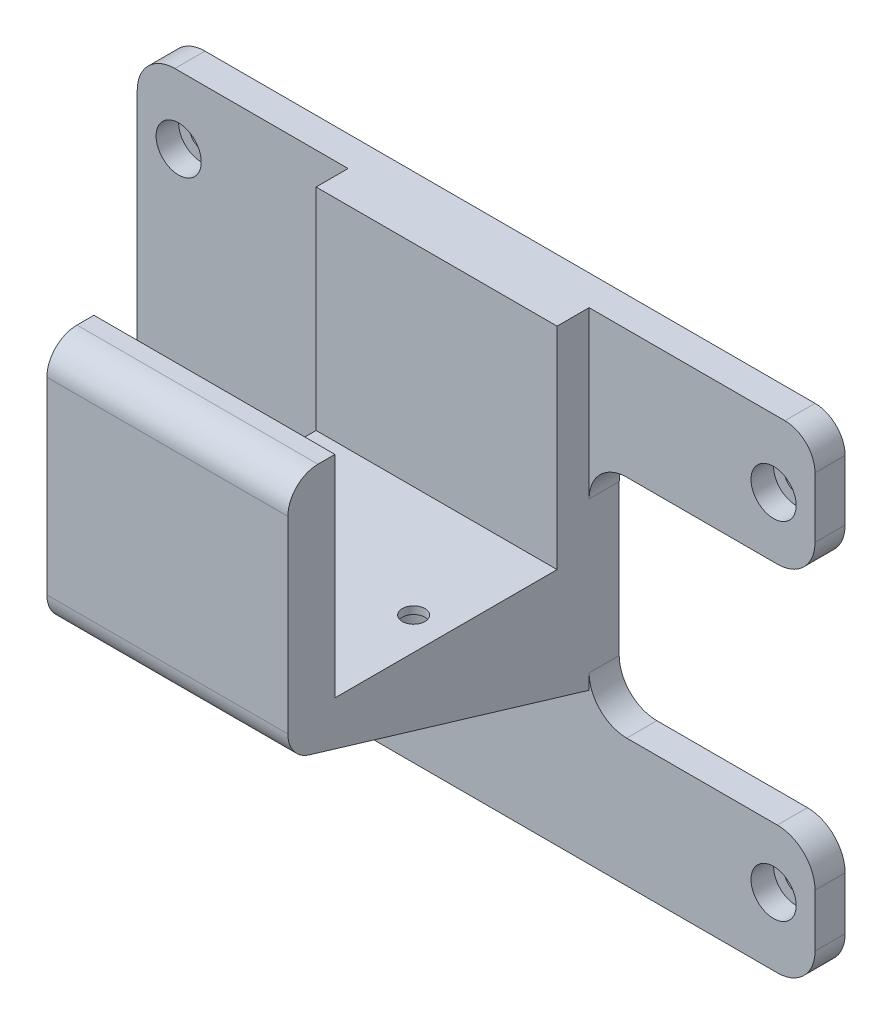
from build123d import *

# Parameters (mm, degrees)
SKETCH_1_R           = 1.5
EXTRUDE_1_DEPTH      = 4
SKETCH_2_R           = 3
CUT_EXTRUDE_1_DEPTH  = 3
SKETCH_3_W           = 32
SKETCH_3_H           = 44
EXTRUDE_2_DEPTH      = 40
SKETCH_4_R           = 1.5
CUT_EXTRUDE_2_DEPTH  = 65
SKETCH_5_R           = 3
CUT_EXTRUDE_10_DEPTH = 15
SKETCH_7_W           = 32
SKETCH_7_H           = 29.5
CUT_EXTRUDE_12_DEPTH = 28
CUT_EXTRUDE_11_DEPTH = 63


with BuildPart() as part:
    # 草图1 → 凸台-拉伸1 (new body)
    with BuildSketch(Plane.XY):
        with BuildLine():
            Line((-40, 32), (41, 32))
            ThreePointArc((41, 32), (43.828427125, 30.828427125), (45, 28))
            Line((45, 28), (45, 20))
            ThreePointArc((45, 20), (43.535533906, 16.464466094), (40, 15))
            Line((40, 15), (20, 15))
            ThreePointArc((20, 15), (16.464466094, 13.535533906), (15, 10))
            Line((15, 10), (15, -10))
            ThreePointArc((15, -10), (16.464466094, -13.535533906), (20, -15))
            Line((20, -15), (40, -15))
            ThreePointArc((40, -15), (43.535533906, -16.464466094), (45, -20))
            Line((45, -20), (45, -27))
            ThreePointArc((45, -27), (43.535533906, -30.535533906), (40, -32))
            Line((40, -32), (-40, -32))
            ThreePointArc((-40, -32), (-43.535533906, -30.535533906), (-45, -27))
            Line((-45, -27), (-45, 27))
            ThreePointArc((-45, 27), (-43.535533906, 30.535533906), (-40, 32))
        make_face()
        with Locations((-39.5, 23)):
            Circle(SKETCH_1_R, mode=Mode.SUBTRACT)
        with Locations((-39.5, -23)):
            Circle(SKETCH_1_R, mode=Mode.SUBTRACT)
        with Locations((39.5, -23)):
            Circle(SKETCH_1_R, mode=Mode.SUBTRACT)
        with Locations((39.5, 23)):
            Circle(SKETCH_1_R, mode=Mode.SUBTRACT)
    extrude(amount=EXTRUDE_1_DEPTH)

    # 草图2 → 切除-拉伸1 (cut)
    with BuildSketch(Plane.XY.offset(4)):
        with Locations((-39.5, 23)):
            Circle(SKETCH_2_R)
        with Locations((-39.5, -23)):
            Circle(SKETCH_2_R)
        with Locations((39.5, -23)):
            Circle(SKETCH_2_R)
        with Locations((39.5, 23)):
            Circle(SKETCH_2_R)
    extrude(amount=-CUT_EXTRUDE_1_DEPTH, mode=Mode.SUBTRACT)

    # 草图3 → 凸台-拉伸2 (add)
    with BuildSketch(Plane.XY.offset(4)):
        with Locations((-1, 10)):
            Rectangle(SKETCH_3_W, SKETCH_3_H)
    extrude(amount=EXTRUDE_2_DEPTH)

    # 草图4 → 切除-拉伸2 (cut, through all)
    with BuildSketch(Plane(origin=(0, 32, 0), x_dir=(1, 0, 0), z_dir=(0, 1, 0))):
        with Locations((-13, -13)):
            Circle(SKETCH_4_R)
        with Locations((-13, -33)):
            Circle(SKETCH_4_R)
        with Locations((10.7, -23)):
            Circle(SKETCH_4_R)
    extrude(amount=-CUT_EXTRUDE_2_DEPTH, mode=Mode.SUBTRACT)

    # 草图5 → 切除-拉伸10 (cut)
    with BuildSketch(Plane.XZ.offset(12)):
        with Locations((-13, 33)):
            Circle(SKETCH_5_R)
        with Locations((-13, 13)):
            Circle(SKETCH_5_R)
        with Locations((10.7, 23)):
            Circle(SKETCH_5_R)
    extrude(amount=-CUT_EXTRUDE_10_DEPTH, mode=Mode.SUBTRACT)

    # 草图7 → 切除-拉伸12 (cut)
    with BuildSketch(Plane(origin=(0, 32, 0), x_dir=(1, 0, 0), z_dir=(0, 1, 0))):
        with Locations((-1, -23)):
            Rectangle(SKETCH_7_W, SKETCH_7_H)
    extrude(amount=-CUT_EXTRUDE_12_DEPTH, mode=Mode.SUBTRACT)

    # 草图6 → 切除-拉伸11 (cut, through all)
    with BuildSketch(Plane.ZY.offset(17)):
        with BuildLine():
            Line((4, -12), (41.149391542, -0.855182537))
            ThreePointArc((41.149391542, -0.855182537), (43.209171713, 0.588400485), (44, 2.976122604))
            Line((44, 2.976122604), (44, -12))
            Line((44, -12), (4, -12))
        make_face()
        with BuildLine():
            Line((40, 32), (44, 32))
            Line((44, 32), (44, 28))
            ThreePointArc((44, 28), (42.828427125, 30.828427125), (40, 32))
        make_face()
    extrude(amount=-CUT_EXTRUDE_11_DEPTH, mode=Mode.SUBTRACT)


solid = part.part
